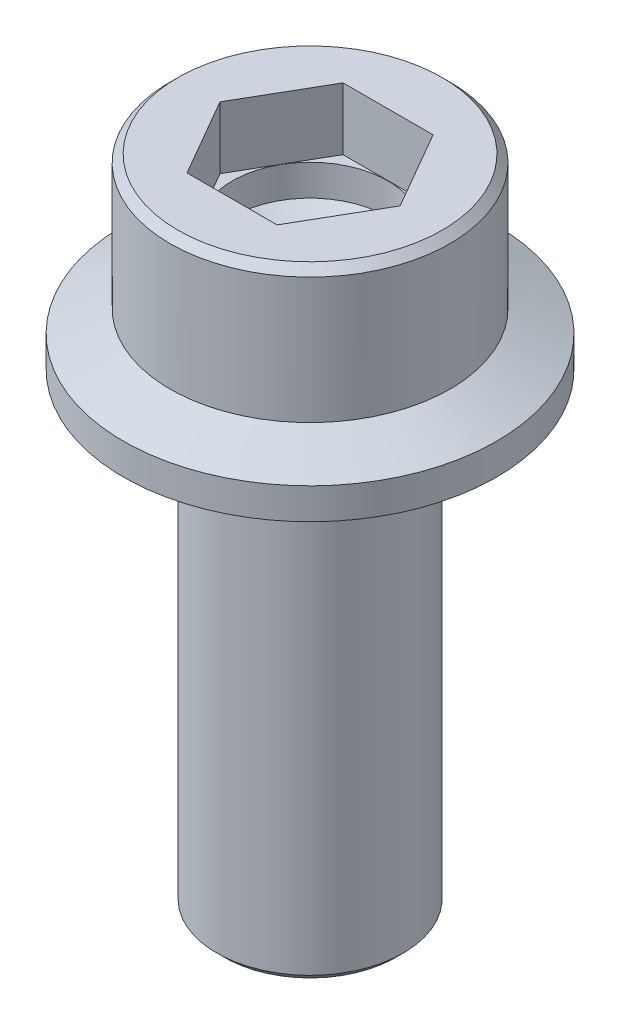
from build123d import *

# Parameters (mm, degrees)
HEX_KEY_1_DEPTH     = 4
CHAMFER_HEAD_SIZE   = 0.5
CHAMFER_THREAD_SIZE = 0.5


with BuildPart() as part:
    # Sketch1 → Main Body (revolve)
    with BuildSketch(Plane.XY, mode=Mode.PRIVATE) as main_body_sk:
        with BuildLine():
            Line((5, 42), (9, 42))
            Line((9, 42), (9, 33.398922974))
            Line((9, 33.398922974), (12, 32))
            Line((12, 32), (12, 30))
            Line((12, 30), (6.4, 30))
            ThreePointArc((6.4, 30), (6.117157288, 29.882842712), (6, 29.6))
            Line((6, 29.6), (6, 0))
            Line((6, 0), (0, 0))
            Line((0, 0), (0, 32.995696905))
            Line((0, 32.995696905), (5, 36))
            Line((5, 36), (5, 42))
        make_face()
    revolve(main_body_sk.sketch.rotate(Axis((0, 0, 0), (0, 1, 0)), 90), axis=Axis((0, 0, 0), (0, 1, 0)))  # turned: the seam where the file's is

    # Sketch2 → Hex Key 1 (cut)
    with BuildSketch(Plane(origin=(0, 42, 0), x_dir=(1, 0, 0), z_dir=(0, 1, 0))):
        Polygon((-5.7908232, 0), (-2.8954116, -5.015), (2.8954116, -5.015), (5.7908232, 0), (2.8954116, 5.015), (-2.8954116, 5.015), align=None)
    extrude(amount=-HEX_KEY_1_DEPTH, mode=Mode.SUBTRACT)

    # Chamfer-Head
    chamfer_head_edges = [part.edges().sort_by_distance(p)[0] for p in [
        (0, 42, 9),
    ]]
    chamfer(chamfer_head_edges, length=CHAMFER_HEAD_SIZE)

    # Chamfer-Thread
    chamfer_thread_edges = [part.edges().sort_by_distance(p)[0] for p in [
        (0, 0, 6),
    ]]
    chamfer(chamfer_thread_edges, length=CHAMFER_THREAD_SIZE)


solid = part.part
